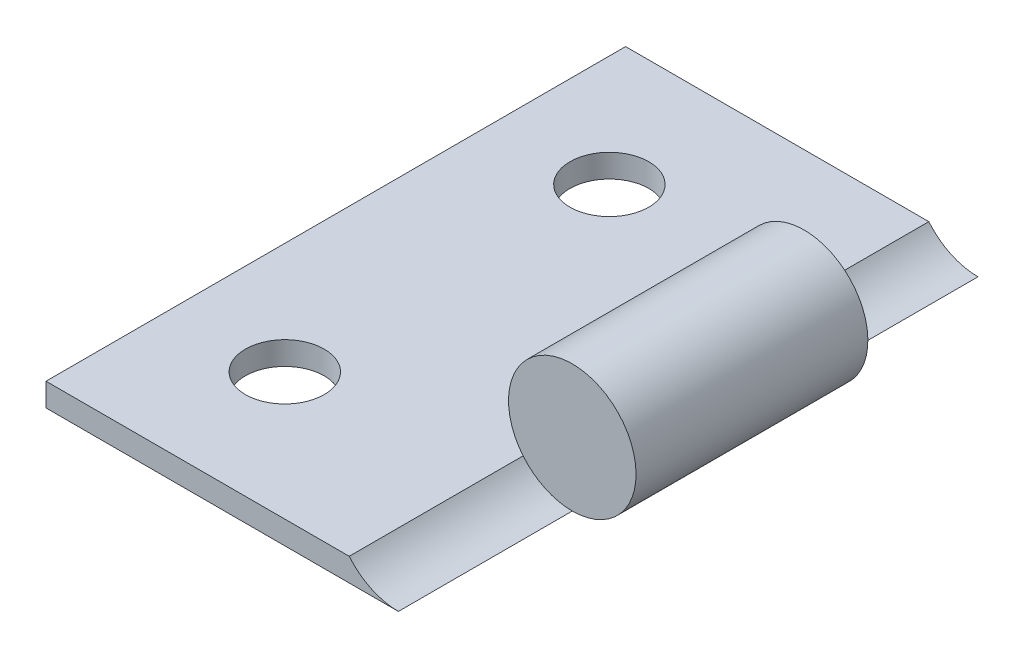
from build123d import *

# Parameters (mm, degrees)
EXTRUDE_1_DEPTH     = 25
SKETCH_2_R          = 1.7
CUT_EXTRUDE_1_DEPTH = 25
SKETCH_3_R          = 2.75
CUT_EXTRUDE_2_DEPTH = 7.5
CUT_EXTRUDE_START   = -25
SKETCH_3_2_R        = 2.75
CUT_EXTRUDE_3_DEPTH = 7.5


with BuildPart() as part:
    # 草图1 → 凸台-拉伸1 (new body)
    with BuildSketch(Plane.XY):
        with BuildLine():
            Line((0, -2.75), (-15.2, -2.75))
            Line((-15.2, -2.75), (-15.2, -1.75))
            Line((-15.2, -1.75), (-2.121320344, -1.75))
            ThreePointArc((-2.121320344, -1.75), (1.17260394, 2.487468593), (0, -2.75))
        make_face()
    extrude(amount=EXTRUDE_1_DEPTH)

    # 草图2 → 切除-拉伸1 (cut)
    with BuildSketch(Plane(origin=(0, -1.75, 0), x_dir=(1, 0, 0), z_dir=(0, 1, 0))):
        with Locations((-10.4, -5.5)):
            Circle(SKETCH_2_R)
        with Locations((-10.4, -19.5)):
            Circle(SKETCH_2_R)
    extrude(amount=-CUT_EXTRUDE_1_DEPTH, mode=Mode.SUBTRACT)

    # 草图3 → 切除-拉伸2 (cut)
    with BuildSketch(Plane(origin=(0, 0, 0), x_dir=(-1, 0, 0), z_dir=(0, 0, -1))):
        Circle(SKETCH_3_R)
    extrude(amount=-CUT_EXTRUDE_2_DEPTH, mode=Mode.SUBTRACT)

    # 草图3<2> → 切除-拉伸3 (cut)
    with BuildSketch(Plane(origin=(0, 0, 0), x_dir=(-1, 0, 0), z_dir=(0, 0, -1)).offset(CUT_EXTRUDE_START)):
        Circle(SKETCH_3_2_R)
    extrude(amount=CUT_EXTRUDE_3_DEPTH, mode=Mode.SUBTRACT)


solid = part.part
